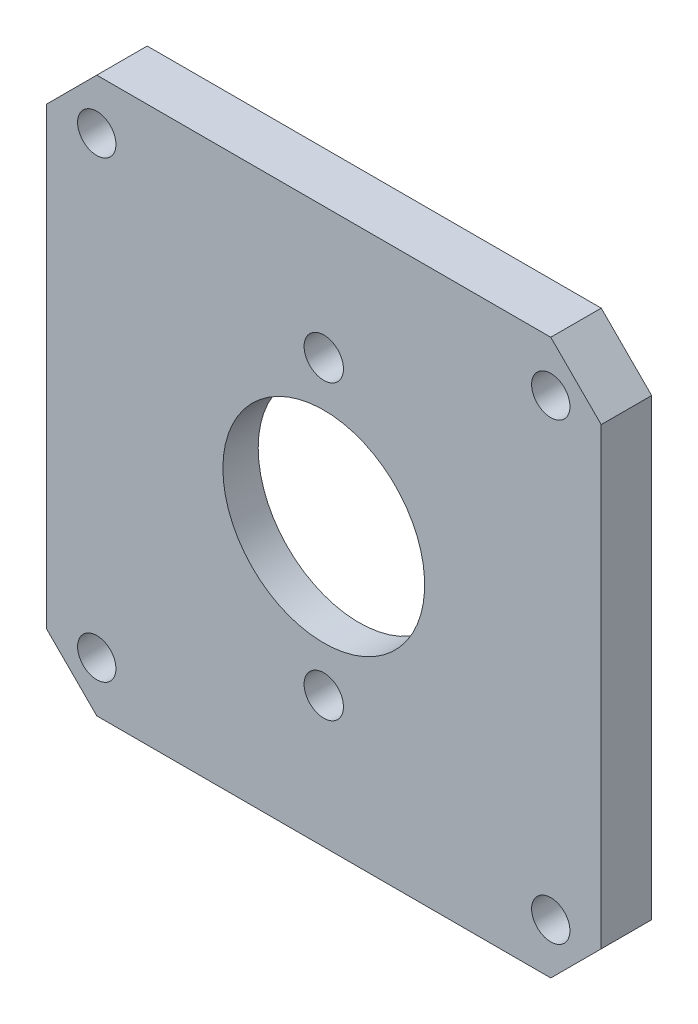
from build123d import *

# Parameters (mm, degrees)
SKETCH1_W           = 55
SKETCH1_H           = 55
BOSS_EXTRUDE1_DEPTH = 5
CHAMFER1_SIZE       = 5
SKETCH2_R           = 1.95
SKETCH2_R_2         = 1.9
SKETCH2_R_3         = 10
CUT_EXTRUDE1_DEPTH  = 10
SKETCH3_R           = 17.5
CUT_EXTRUDE2_DEPTH  = 1.5


with BuildPart() as part:
    # Sketch1 → Boss-Extrude1 (new body)
    with BuildSketch(Plane.XY):
        Rectangle(SKETCH1_W, SKETCH1_H)
    extrude(amount=BOSS_EXTRUDE1_DEPTH)

    # Chamfer1
    chamfer1_edges = [part.edges().sort_by_distance(p)[0] for p in [
        (-27.5, -27.5, 2.5),
        (27.5, -27.5, 2.5),
        (27.5, 27.5, 2.5),
        (-27.5, 27.5, 2.5),
    ]]
    chamfer(chamfer1_edges, length=CHAMFER1_SIZE)

    # Sketch2 → Cut-Extrude1 (cut)
    with BuildSketch(Plane(origin=(0, 0, 0), x_dir=(-1, 0, 0), z_dir=(0, 0, -1))):
        with Locations((0, 14.5)):
            Circle(SKETCH2_R)
        with Locations((-22.5, 22.5)):
            Circle(SKETCH2_R_2)
        with Locations((22.5, 22.5)):
            Circle(SKETCH2_R_2)
        with Locations((22.5, -22.5)):
            Circle(SKETCH2_R_2)
        with Locations((-22.5, -22.5)):
            Circle(SKETCH2_R_2)
        Circle(SKETCH2_R_3)
        with Locations((0, -14.5)):
            Circle(SKETCH2_R)
    extrude(amount=-CUT_EXTRUDE1_DEPTH, mode=Mode.SUBTRACT)

    # Sketch3 → Cut-Extrude2 (cut)
    with BuildSketch(Plane(origin=(0, 0, 0), x_dir=(-1, 0, 0), z_dir=(0, 0, -1))):
        Circle(SKETCH3_R)
    extrude(amount=-CUT_EXTRUDE2_DEPTH, mode=Mode.SUBTRACT)


solid = part.part
